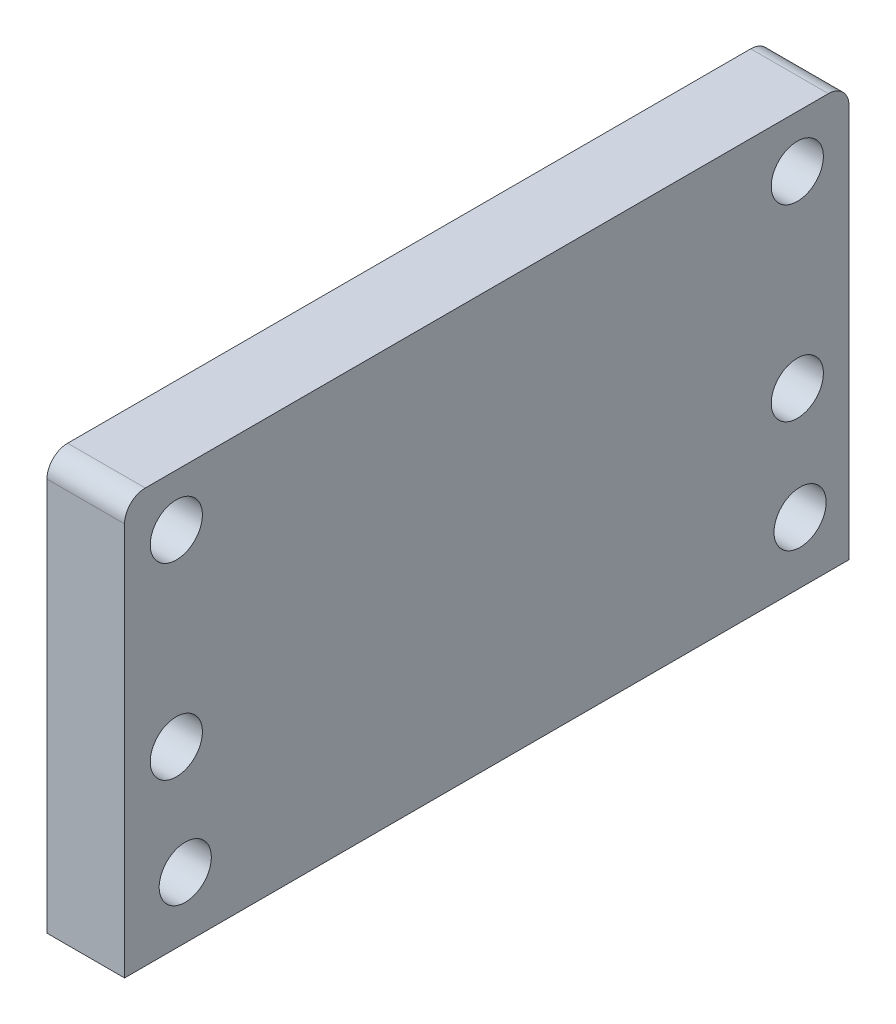
from build123d import *

# Parameters (mm, degrees)
SKETCH1_W           = 88.9
SKETCH1_H           = 50.8
BOSS_EXTRUDE1_DEPTH = 4.7625
SKETCH2_R           = 3.2
CUT_EXTRUDE1_DEPTH  = 10.525
FILLET3_R           = 2.54
FILLET4_R           = 2.54
SKETCH4_R           = 3.2
CUT_EXTRUDE5_DEPTH  = 10.525


with BuildPart() as part:
    # Sketch1 → Boss-Extrude1 (new body, symmetric)
    with BuildSketch(Plane(origin=(0, 0, 0), x_dir=(0, 0, -1), z_dir=(1, 0, 0))):
        Rectangle(SKETCH1_W, SKETCH1_H)
    extrude(amount=BOSS_EXTRUDE1_DEPTH, both=True)

    # Sketch2 → Cut-Extrude1 (cut, through all)
    with BuildSketch(Plane(origin=(4.7625, 0, 0), x_dir=(0, 0, -1), z_dir=(1, 0, 0))):
        with Locations((-38.1, 19.05)):
            Circle(SKETCH2_R)
        with Locations((38.1, 19.05)):
            Circle(SKETCH2_R)
        with Locations((-38.1, -4)):
            Circle(SKETCH2_R)
        with Locations((38.1, -4)):
            Circle(SKETCH2_R)
    extrude(amount=-CUT_EXTRUDE1_DEPTH, mode=Mode.SUBTRACT)

    # Fillet3
    fillet3_edges = [part.edges().sort_by_distance(p)[0] for p in [
        (0, 25.4, 44.45),
    ]]
    fillet(fillet3_edges, radius=FILLET3_R)

    # Fillet4
    fillet4_edges = [part.edges().sort_by_distance(p)[0] for p in [
        (0, 25.4, -44.45),
    ]]
    fillet(fillet4_edges, radius=FILLET4_R)

    # Sketch4 → Cut-Extrude5 (cut, through all)
    with BuildSketch(Plane(origin=(4.7625, 0, 0), x_dir=(0, 0, -1), z_dir=(1, 0, 0))):
        with Locations((-37.002111381, -17.879327913)):
            Circle(SKETCH4_R)
        with Locations((38.440338437, -17.879327913)):
            Circle(SKETCH4_R)
    extrude(amount=-CUT_EXTRUDE5_DEPTH, mode=Mode.SUBTRACT)


solid = part.part
